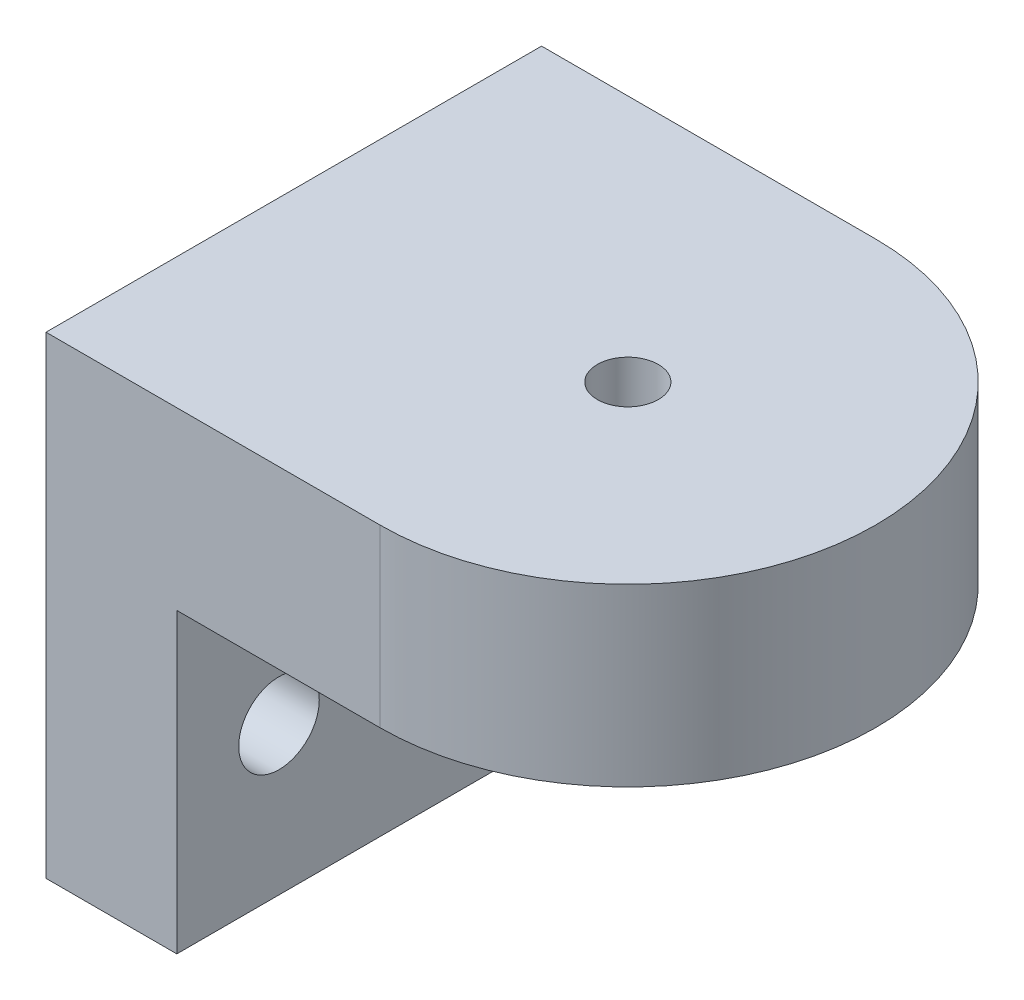
from build123d import *

# Parameters (mm, degrees)
SKETCH1_W           = 34.0614
SKETCH1_H           = 32.512
BOSS_EXTRUDE1_DEPTH = 8.9916
SKETCH2_W           = 34.0614
SKETCH2_H           = 12.065
BOSS_EXTRUDE2_DEPTH = 13.97
SKETCH3_W           = 17.0307
SKETCH3_H           = 12.065
REVOLVE1_ANGLE      = 180
SKETCH4_R           = 2.0955
CUT_EXTRUDE1_DEPTH  = 7.62
CUT_EXTRUDE2_REACH  = 10.992
SKETCH5_R           = 2.7686
SKETCH5_R_2         = 2.6416


with BuildPart() as part:
    # Sketch1 → Boss-Extrude1 (new body)
    with BuildSketch(Plane(origin=(0, 0, 0), x_dir=(0, 0, -1), z_dir=(1, 0, 0))):
        Rectangle(SKETCH1_W, SKETCH1_H)
    extrude(amount=BOSS_EXTRUDE1_DEPTH)

    # Sketch2 → Boss-Extrude2 (add)
    with BuildSketch(Plane(origin=(8.9916, 0, 0), x_dir=(0, 0, -1), z_dir=(1, 0, 0))):
        with Locations((0, 10.2235)):
            Rectangle(SKETCH2_W, SKETCH2_H)
    extrude(amount=BOSS_EXTRUDE2_DEPTH)

    # Sketch3 → Revolve1 (revolve)
    with BuildSketch(Plane(origin=(22.9616, 0, 0), x_dir=(0, 0, -1), z_dir=(1, 0, 0))):
        with Locations((8.51535, 10.2235)):
            Rectangle(SKETCH3_W, SKETCH3_H)
    revolve(axis=Axis((22.9616, 16.256, 0), (0, -1, 0)), revolution_arc=REVOLVE1_ANGLE)

    # Sketch4 → Cut-Extrude1 (cut)
    with BuildSketch(Plane(origin=(0, 16.256, 0), x_dir=(1, 0, 0), z_dir=(0, 1, 0))):
        with Locations((22.9616, 0)):
            Circle(SKETCH4_R)
    extrude(amount=-CUT_EXTRUDE1_DEPTH, mode=Mode.SUBTRACT)

    # Sketch5 → Cut-Extrude2 (cut, up to next)
    with BuildSketch(Plane(origin=(8.9916, 0, 0), x_dir=(0, 0, -1), z_dir=(1, 0, 0)), mode=Mode.PRIVATE) as cut_extrude2_sk1:
        with Locations((-10.0076, -6.0325)):
            Circle(SKETCH5_R)
    cut_extrude2_tool1 = extrude(cut_extrude2_sk1.sketch, amount=-CUT_EXTRUDE2_REACH, mode=Mode.PRIVATE) & part.part
    add(cut_extrude2_tool1.solids().sort_by_distance((8.9916, -6.0325, 10.0076))[0], mode=Mode.SUBTRACT)
    # Sketch5 → Cut-Extrude2 (cut, up to next)
    with BuildSketch(Plane(origin=(8.9916, 0, 0), x_dir=(0, 0, -1), z_dir=(1, 0, 0)), mode=Mode.PRIVATE) as cut_extrude2_sk2:
        with Locations((10.0076, -6.0325)):
            Circle(SKETCH5_R_2)
    cut_extrude2_tool2 = extrude(cut_extrude2_sk2.sketch, amount=-CUT_EXTRUDE2_REACH, mode=Mode.PRIVATE) & part.part
    add(cut_extrude2_tool2.solids().sort_by_distance((8.9916, -6.0325, -10.0076))[0], mode=Mode.SUBTRACT)


solid = part.part
